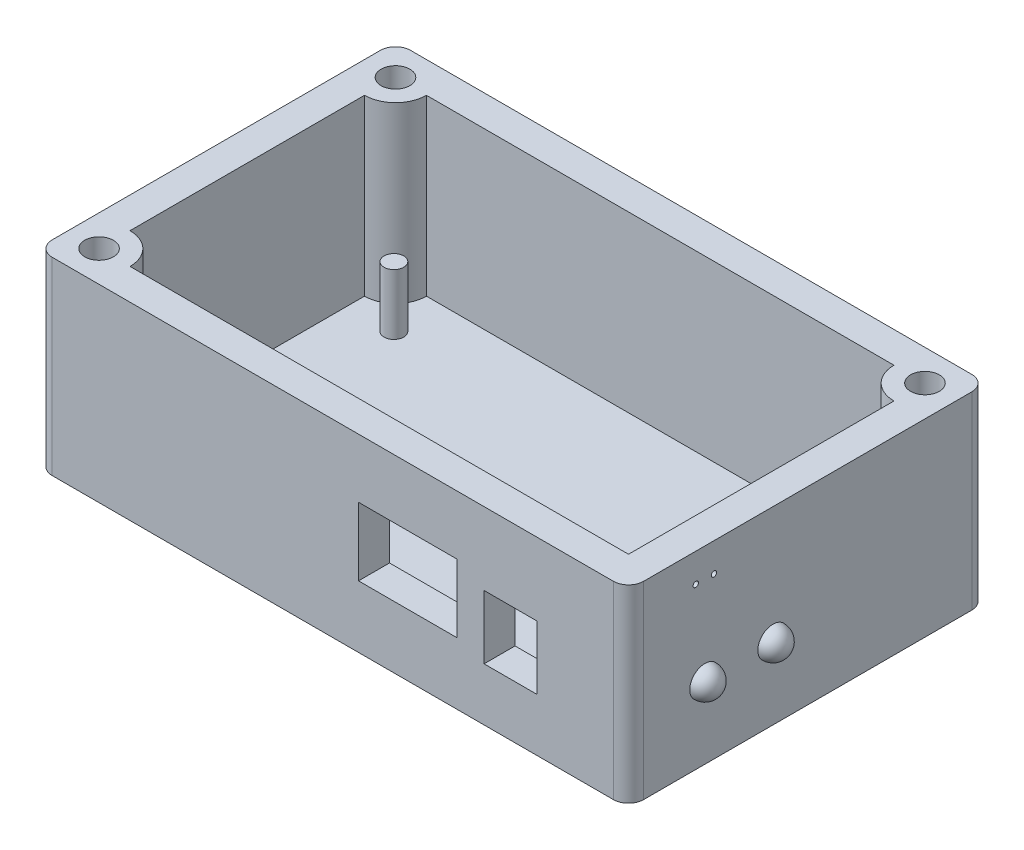
from build123d import *

# Parameters (mm, degrees)
SKETCH1_W           = 99.30160125
SKETCH1_H           = 60.173202502
BOSS_EXTRUDE1_DEPTH = 29.21
SKETCH1_23_W        = 99.30160125
SKETCH1_23_H        = 60.173202502
BOSS_EXTRUDE2_DEPTH = 2.54
CUT_EXTRUDE1_START  = 29.21
SKETCH1_25_R        = 2.413
CUT_EXTRUDE1_DEPTH  = 12.192
SKETCH1_28_R        = 1.651
BOSS_EXTRUDE5_DEPTH = 10.16
SKETCH6_W           = 8.89
SKETCH6_H           = 10.668
CUT_EXTRUDE2_DEPTH  = 10.16
SKETCH8_W           = 16.51
SKETCH8_H           = 11.43
CUT_EXTRUDE4_DEPTH  = 10.16
SKETCH10_R          = 2.032
CUT_EXTRUDE7_DEPTH  = 6.200800625
REVOLVE1_ANGLE      = 180
REVOLVE2_ANGLE      = 180
SKETCH13_R          = 0.45
CUT_EXTRUDE8_DEPTH  = 7.62
FILLET2_R           = 2.54


with BuildPart() as part:
    # Sketch1 → Boss-Extrude1 (new body)
    with BuildSketch(Plane(origin=(0, 0, 0), x_dir=(1, 0, 0), z_dir=(0, 1, 0))):
        Rectangle(SKETCH1_W, SKETCH1_H)
        with BuildLine():
            ThreePointArc((-44.45, 19.685), (-40.77247861, 21.208279236), (-39.249199375, 24.885800625))
            Line((-39.249199375, 24.885800625), (39.249199375, 24.885800625))
            ThreePointArc((39.249199375, 24.885800625), (40.77247861, 21.208279236), (44.45, 19.685))
            Line((44.45, 19.685), (44.45, -24.885800625))
            Line((44.45, -24.885800625), (-39.249199375, -24.885800625))
            ThreePointArc((-39.249199375, -24.885800625), (-40.77247861, -21.208279236), (-44.45, -19.685))
            Line((-44.45, -19.685), (-44.45, 19.685))
        make_face(mode=Mode.SUBTRACT)
    extrude(amount=BOSS_EXTRUDE1_DEPTH)

    # Sketch1_23 → Boss-Extrude2 (add)
    with BuildSketch(Plane(origin=(0, 0, 0), x_dir=(1, 0, 0), z_dir=(0, 1, 0))):
        Rectangle(SKETCH1_23_W, SKETCH1_23_H)
    extrude(amount=-BOSS_EXTRUDE2_DEPTH)

    # Sketch1_25 → Cut-Extrude1 (cut)
    with BuildSketch(Plane(origin=(0, 0, 0), x_dir=(1, 0, 0), z_dir=(0, 1, 0)).offset(CUT_EXTRUDE1_START)):
        with Locations((-44.45, 24.885800625)):
            Circle(SKETCH1_25_R)
        with Locations((44.45, 24.885800625)):
            Circle(SKETCH1_25_R)
        with Locations((-44.45, -24.885800625)):
            Circle(SKETCH1_25_R)
    extrude(amount=-CUT_EXTRUDE1_DEPTH, mode=Mode.SUBTRACT)

    # Sketch1_28 → Boss-Extrude5 (add)
    with BuildSketch(Plane(origin=(0, 0, 0), x_dir=(1, 0, 0), z_dir=(0, 1, 0))):
        with Locations((42.186757457, 17.024199375)):
            Circle(SKETCH1_28_R)
        with Locations((-36.852757457, -22.225)):
            Circle(SKETCH1_28_R)
        with Locations((-36.852757457, 17.024199375)):
            Circle(SKETCH1_28_R)
        with Locations((42.186757457, -22.225)):
            Circle(SKETCH1_28_R)
    extrude(amount=BOSS_EXTRUDE5_DEPTH)

    # Sketch6 → Cut-Extrude2 (cut)
    with BuildSketch(Plane(origin=(0, 0, 24.885800625), x_dir=(-1, 0, 0), z_dir=(0, 0, -1))):
        with Locations((-29.845, 11.684)):
            Rectangle(SKETCH6_W, SKETCH6_H)
    extrude(amount=-CUT_EXTRUDE2_DEPTH, mode=Mode.SUBTRACT)

    # Sketch8 → Cut-Extrude4 (cut)
    with BuildSketch(Plane.XY.offset(30.086601251)):
        with Locations((12.573, 13.589)):
            Rectangle(SKETCH8_W, SKETCH8_H)
    extrude(amount=-CUT_EXTRUDE4_DEPTH, mode=Mode.SUBTRACT)

    # Sketch10 → Cut-Extrude7 (cut, through all)
    with BuildSketch(Plane.ZY.offset(-44.45)):
        with Locations((17.265800625, 9.5758)):
            Circle(SKETCH10_R)
        with Locations((5.835800625, 9.5758)):
            Circle(SKETCH10_R)
    extrude(amount=-CUT_EXTRUDE7_DEPTH, mode=Mode.SUBTRACT)

    # Sketch12 → Revolve1 (revolve)
    with BuildSketch(Plane(origin=(49.650800625, 0, 0), x_dir=(0, 0, -1), z_dir=(1, 0, 0))):
        with BuildLine():
            Line((-17.265800625, 11.6078), (-17.265800625, 12.1158))
            ThreePointArc((-17.265800625, 12.1158), (-19.805800625, 9.5758), (-17.265800625, 7.0358))
            Line((-17.265800625, 7.0358), (-17.265800625, 7.5438))
            ThreePointArc((-17.265800625, 7.5438), (-19.297800625, 9.5758), (-17.265800625, 11.6078))
        make_face()
    revolve(axis=Axis((49.650800625, 12.1158, 17.265800625), (0, 1, 0)), revolution_arc=REVOLVE1_ANGLE)

    # Sketch12_4 → Revolve2 (revolve)
    with BuildSketch(Plane(origin=(49.650800625, 0, 0), x_dir=(0, 0, -1), z_dir=(1, 0, 0))):
        with BuildLine():
            ThreePointArc((-5.835800625, 7.0358), (-3.295800625, 9.5758), (-5.835800625, 12.1158))
            Line((-5.835800625, 12.1158), (-5.835800625, 11.6078))
            ThreePointArc((-5.835800625, 11.6078), (-3.803800625, 9.5758), (-5.835800625, 7.5438))
            Line((-5.835800625, 7.5438), (-5.835800625, 7.0358))
        make_face()
    revolve(axis=Axis((49.650800625, 12.1158, 5.835800625), (0, -1, 0)), revolution_arc=REVOLVE2_ANGLE)

    # Sketch13 → Cut-Extrude8 (cut)
    with BuildSketch(Plane(origin=(49.650800625, 0, 0), x_dir=(0, 0, -1), z_dir=(1, 0, 0))):
        with Locations((-18.789800625, 24.384)):
            Circle(SKETCH13_R)
        with Locations((-15.741800625, 24.384)):
            Circle(SKETCH13_R)
    extrude(amount=-CUT_EXTRUDE8_DEPTH, mode=Mode.SUBTRACT)

    # Fillet2
    fillet2_edges = [part.edges().sort_by_distance(p)[0] for p in [
        (-49.650800625, 13.335, -30.086601251),
        (49.650800625, 13.335, -30.086601251),
        (49.650800625, 13.335, 30.086601251),
        (-49.650800625, 13.335, 30.086601251),
    ]]
    fillet(fillet2_edges, radius=FILLET2_R)


solid = part.part
